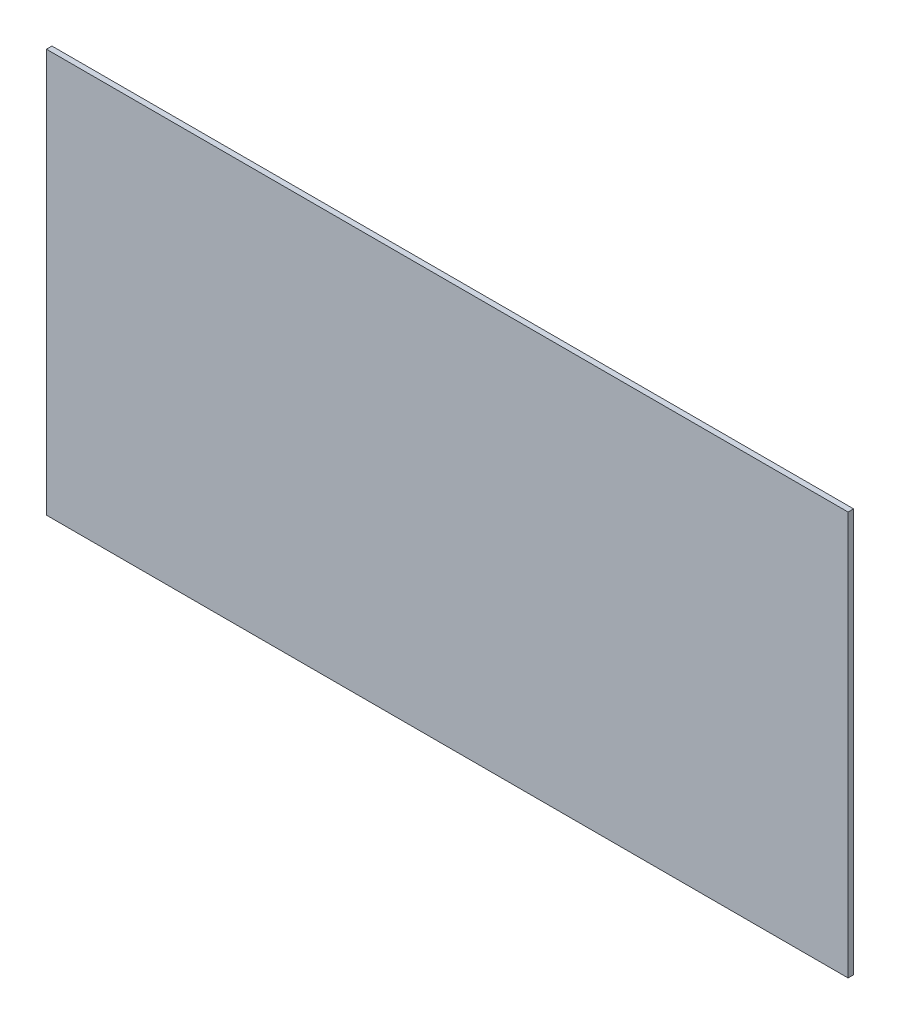
from build123d import *

# Parameters (mm, degrees)
SKETCH1_W           = 291.2
SKETCH1_H           = 146.59
BOSS_EXTRUDE1_DEPTH = 2


with BuildPart() as part:
    # Sketch1 → Boss-Extrude1 (new body)
    with BuildSketch(Plane.XY):
        with Locations((-145.6, 73.295)):
            Rectangle(SKETCH1_W, SKETCH1_H)
    extrude(amount=BOSS_EXTRUDE1_DEPTH)


solid = part.part
